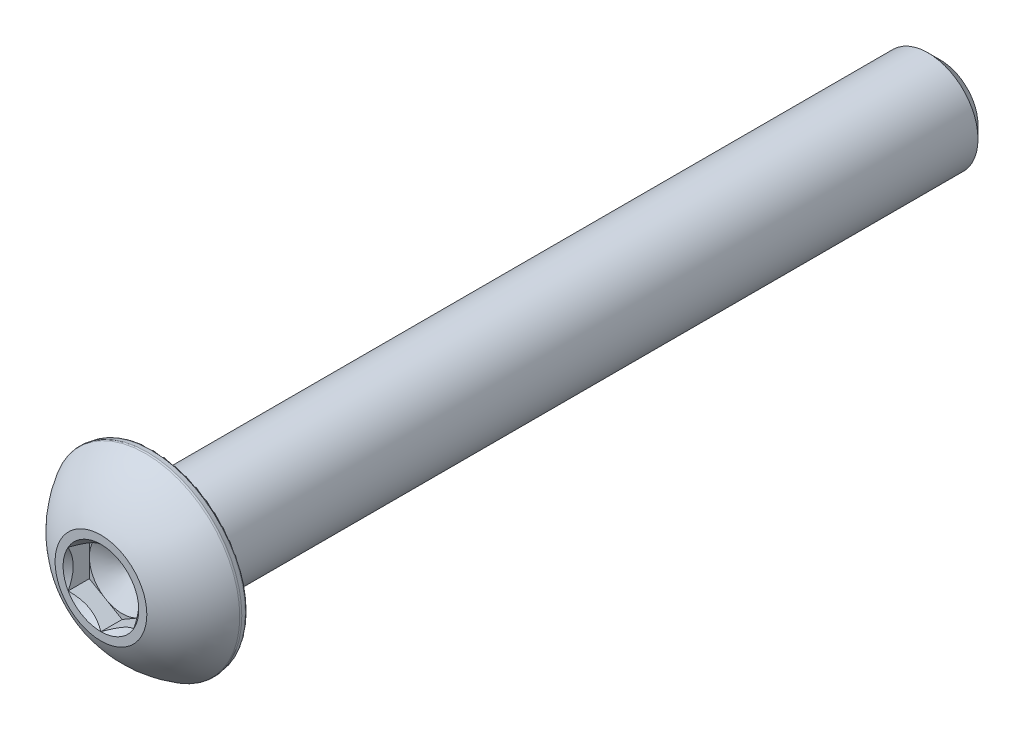
from build123d import *

# Parameters (mm, degrees)
CUT_EXTRUDE1_START = 19.30654
CUT_EXTRUDE1_DEPTH = 2.02616
SKETCH4_R          = 1.833087105
CUT_EXTRUDE2_DEPTH = 1.02616
CUT_EXTRUDE2_DRAFT = -45
FILLET1_R          = 0.12827


with BuildPart() as part:
    # Sketch2 → Revolve1 (revolve)
    with BuildSketch(Plane(origin=(0, 0, 0), x_dir=(0, 0, -1), z_dir=(1, 0, 0))):
        with BuildLine():
            Line((-20.3327, 1.5875), (-20.3327, 2.2225))
            ThreePointArc((-20.3327, 2.2225), (-19.417752118, 3.57733025), (-18.130157143, 4.5847))
            Line((-18.130157143, 4.5847), (-17.7673, 4.520718496))
            Line((-17.7673, 4.520718496), (-17.7673, 2.413))
            Line((-17.7673, 2.413), (19.7373875, 2.413))
            Line((19.7373875, 2.413), (20.3327, 1.8176875))
            Line((20.3327, 1.8176875), (20.3327, 0))
            Line((20.3327, 0), (-18.389996448, 0))
            Line((-18.389996448, 0), (-19.30654, 1.5875))
            Line((-19.30654, 1.5875), (-20.3327, 1.5875))
        make_face()
    revolve(axis=Axis((0, 0, 20.3327), (0, 0, -1)))

    # Sketch3 → Cut-Extrude1 (cut, through all)
    with BuildSketch(Plane.XY.offset(CUT_EXTRUDE1_START)):
        Polygon((0, 1.833087105), (-1.5875, 0.916543552), (-1.5875, -0.916543552), (0, -1.833087105), (1.5875, -0.916543552), (1.5875, 0.916543552), align=None)
    extrude(amount=CUT_EXTRUDE1_DEPTH, mode=Mode.SUBTRACT)


with BuildPart() as cut_extrude2_tool:
    # Sketch4 → Cut-Extrude2 (with draft: the straight prism first)
    with BuildSketch(Plane.XY.offset(20.3327)):
        Circle(SKETCH4_R)
    extrude(amount=-CUT_EXTRUDE2_DEPTH)
    # Cut-Extrude2: the draft: its side faces are tilted about the plane it starts from
    cut_extrude2_sides = [cut_extrude2_tool.faces().sort_by_distance(p)[0] for p in [
        (-1.833087105, 0, 19.81962),
    ]]
    draft(cut_extrude2_sides, Plane.XY.offset(20.3327), CUT_EXTRUDE2_DRAFT)


with BuildPart() as part_1:
    add(part.part)

    # Cut-Extrude2: cut by cut_extrude2_tool
    add(cut_extrude2_tool.part, mode=Mode.SUBTRACT)

    # Fillet1
    fillet1_edges = [part_1.edges().sort_by_distance(p)[0] for p in [
        (0, -4.520718496, 17.7673),
        (0, -4.5847, 18.130157143),
    ]]
    fillet(fillet1_edges, radius=FILLET1_R)


solid = part_1.part
